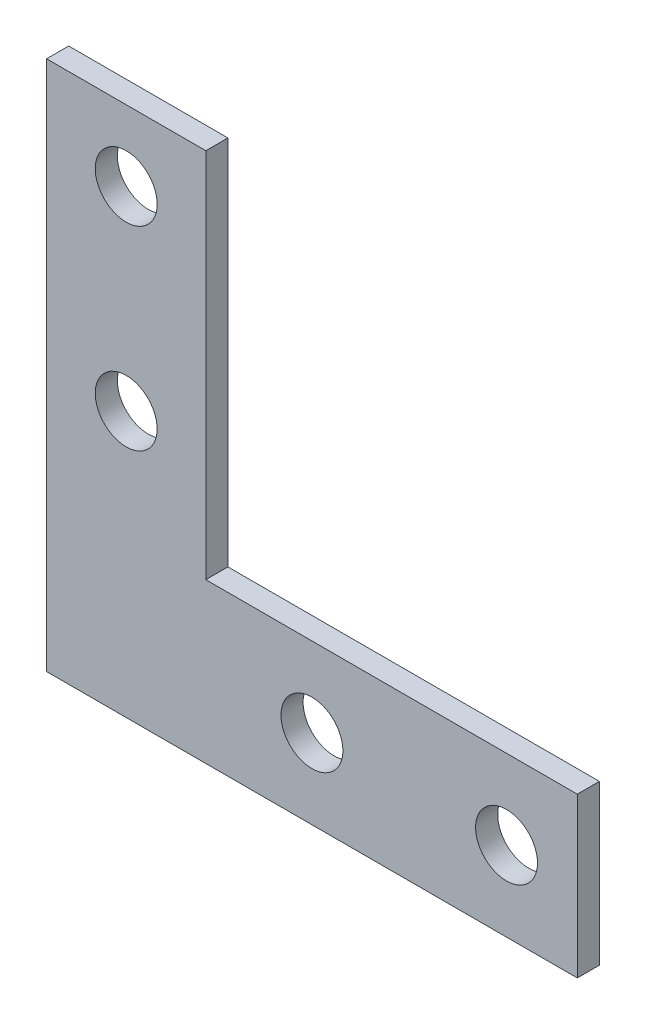
from build123d import *

# Parameters (mm, degrees)
SKETCH_1_R      = 3.5
EXTRUDE_1_DEPTH = 2.5


with BuildPart() as part:
    # Эскиз1 → Бобышка-Вытянуть1 (new body)
    with BuildSketch(Plane.XY):
        Polygon((0, 60), (0, 0), (60, 0), (60, 18), (18, 18), (18, 60), align=None)
        with Locations((9, 52)):
            Circle(SKETCH_1_R, mode=Mode.SUBTRACT)
        with Locations((9, 30)):
            Circle(SKETCH_1_R, mode=Mode.SUBTRACT)
        with Locations((30, 9)):
            Circle(SKETCH_1_R, mode=Mode.SUBTRACT)
        with Locations((52, 9)):
            Circle(SKETCH_1_R, mode=Mode.SUBTRACT)
    extrude(amount=EXTRUDE_1_DEPTH)


solid = part.part
